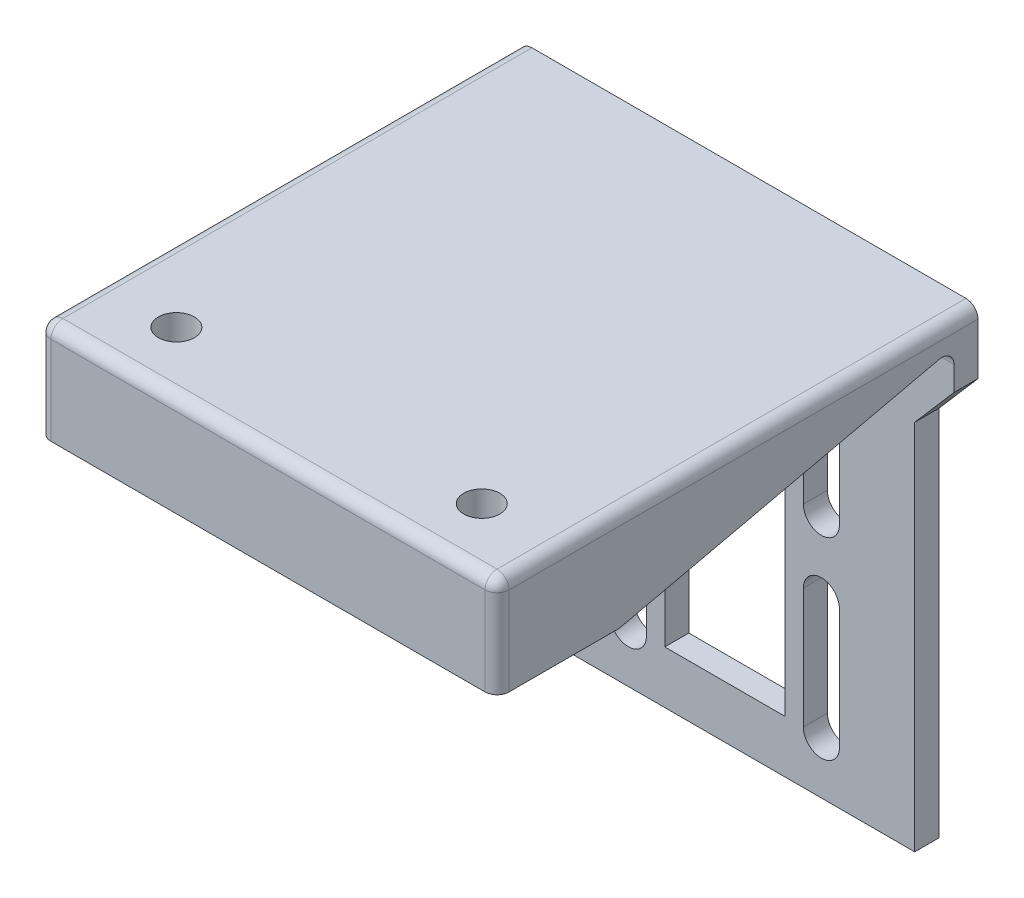
from build123d import *

# Parameters (mm, degrees)
BOSS_EXTRUDE1_DEPTH = 19.05
SKETCH3_W           = 5
SKETCH3_H           = 26.05
CUT_EXTRUDE2_DEPTH  = 3
BOSS_EXTRUDE2_DEPTH = 38.1
SKETCH5_R           = 1.5
CUT_EXTRUDE3_DEPTH  = 8.35
FILLET1_R           = 1


with BuildPart() as part:
    # Sketch1 → Boss-Extrude1 (new body, symmetric)
    with BuildSketch(Plane(origin=(0, 0, 0), x_dir=(0, 0, -1), z_dir=(1, 0, 0))):
        Polygon((0, 0), (-2, 0), (-2, 38), (-40, 38), (-40, 40), (0, 40), align=None)
    extrude(amount=BOSS_EXTRUDE1_DEPTH, both=True)

    # Sketch3 → Cut-Extrude2 (cut, through all)
    with BuildSketch(Plane.XY.offset(2)):
        with Locations((2.5, 17.394531681)):
            Rectangle(SKETCH3_W, SKETCH3_H)
        with Locations((-2.5, 17.394531681)):
            Rectangle(SKETCH3_W, SKETCH3_H)
        with BuildLine():
            Line((-9.525, 30.419531681), (-9.525, 20.419531681))
            ThreePointArc((-9.525, 20.419531681), (-8.025, 18.919531681), (-6.525, 20.419531681))
            Line((-6.525, 20.419531681), (-6.525, 30.419531681))
            ThreePointArc((-6.525, 30.419531681), (-8.025, 31.919531681), (-9.525, 30.419531681))
        make_face()
        with BuildLine():
            Line((-9.525, 14.369531681), (-9.525, 4.369531681))
            ThreePointArc((-9.525, 4.369531681), (-8.025, 2.869531681), (-6.525, 4.369531681))
            Line((-6.525, 4.369531681), (-6.525, 14.369531681))
            ThreePointArc((-6.525, 14.369531681), (-8.025, 15.869531681), (-9.525, 14.369531681))
        make_face()
        with BuildLine():
            ThreePointArc((9.525, 20.419531681), (8.025, 18.919531681), (6.525, 20.419531681))
            Line((6.525, 20.419531681), (6.525, 30.419531681))
            ThreePointArc((6.525, 30.419531681), (8.025, 31.919531681), (9.525, 30.419531681))
            Line((9.525, 30.419531681), (9.525, 20.419531681))
        make_face()
        with BuildLine():
            ThreePointArc((9.525, 4.369531681), (8.025, 2.869531681), (6.525, 4.369531681))
            Line((6.525, 4.369531681), (6.525, 14.369531681))
            ThreePointArc((6.525, 14.369531681), (8.025, 15.869531681), (9.525, 14.369531681))
            Line((9.525, 14.369531681), (9.525, 4.369531681))
        make_face()
        Polygon((-15.786412439, 30.942427664), (-19.05, 34.716026675), (-19.05, 0), (-15.786412439, 0), align=None)
        Polygon((15.786412439, 30.942427664), (15.786412439, 0), (19.05, 0), (19.05, 34.716026675), align=None)
    extrude(amount=-CUT_EXTRUDE2_DEPTH, mode=Mode.SUBTRACT)

    # Sketch4 → Boss-Extrude2 (add)
    with BuildSketch(Plane(origin=(19.05, 0, 0), x_dir=(0, 0, -1), z_dir=(1, 0, 0))):
        Polygon((-2, 38), (-29.84, 31.65), (-40, 31.65), (-40, 38), align=None)
    extrude(amount=-BOSS_EXTRUDE2_DEPTH)

    # Sketch5 → Cut-Extrude3 (cut)
    with BuildSketch(Plane(origin=(0, 40, 0), x_dir=(1, 0, 0), z_dir=(0, 1, 0))):
        with Locations((-12.7, -34.92)):
            Circle(SKETCH5_R)
        with Locations((12.7, -34.92)):
            Circle(SKETCH5_R)
    extrude(amount=-CUT_EXTRUDE3_DEPTH, mode=Mode.SUBTRACT)

    # Fillet1
    fillet1_edges = [part.edges().sort_by_distance(p)[0] for p in [
        (0, 38, 2),
        (0, 40, 40),
        (0, 31.65, 29.84),
        (19.05, 35.825, 40),
        (-19.05, 35.825, 40),
        (-19.05, 40, 20),
        (19.05, 40, 20),
    ]]
    fillet(fillet1_edges, radius=FILLET1_R)


solid = part.part
